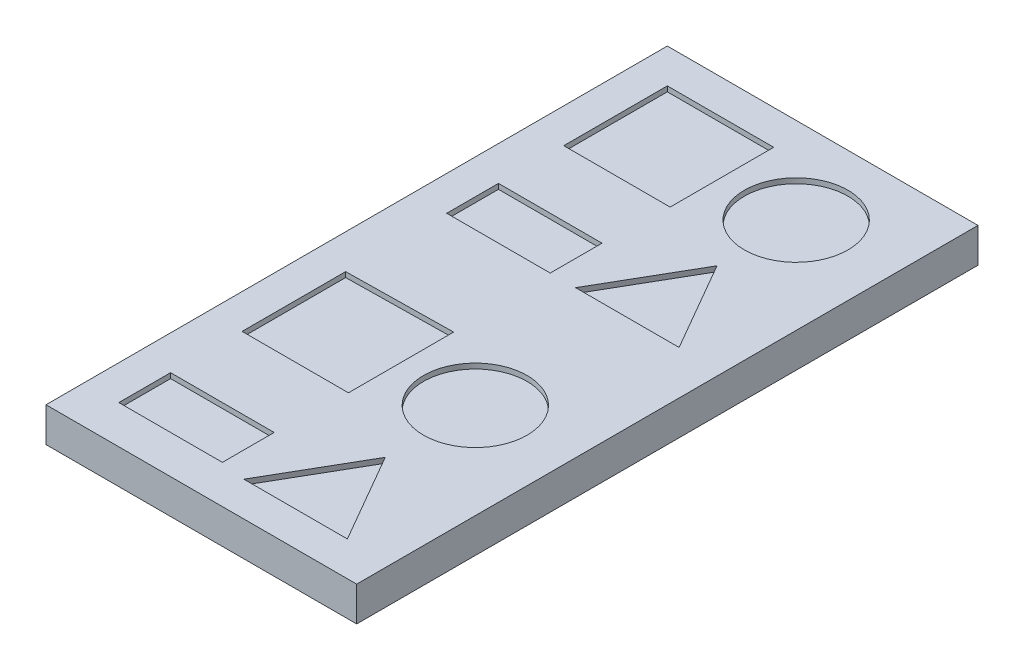
from build123d import *

# Parameters (mm, degrees)
SKETCH1_W           = 180
SKETCH1_H           = 360
BOSS_EXTRUDE1_DEPTH = 20
SKETCH2_R           = 30
SKETCH2_W           = 60
SKETCH2_H           = 30
SKETCH2_W_2         = 61.624654561
SKETCH2_H_2         = 60
CUT_EXTRUDE1_DEPTH  = 3


with BuildPart() as part:
    # Sketch1 → Boss-Extrude1 (new body)
    with BuildSketch(Plane(origin=(0, 0, 0), x_dir=(1, 0, 0), z_dir=(0, 1, 0))):
        Rectangle(SKETCH1_W, SKETCH1_H)
    extrude(amount=-BOSS_EXTRUDE1_DEPTH)

    # Sketch2 → Cut-Extrude1 (cut)
    with BuildSketch(Plane(origin=(0, 0, 0), x_dir=(1, 0, 0), z_dir=(0, 1, 0))):
        with Locations((34.656170811, 130)):
            Circle(SKETCH2_R)
        with Locations((34.656170811, -55.914468779)):
            Circle(SKETCH2_R)
        with Locations((-40, 47.162192329)):
            Rectangle(SKETCH2_W, SKETCH2_H)
        with Locations((-39.18767272, 130)):
            Rectangle(SKETCH2_W_2, SKETCH2_H_2)
        Polygon((4.656170811, 32.162192329), (64.656170811, 32.162192329), (34.656170811, 84.123716556), align=None)
        Polygon((4.656170811, -160.040110734), (64.656170811, -160.040110734), (34.656170811, -108.078586507), align=None)
        with Locations((-40, -142.801384824)):
            Rectangle(SKETCH2_W, SKETCH2_H)
        Polygon((-8.375345439, -25.441495932), (-8.375345439, -86.387441626), (-70, -86.387441626), (-70, -26.387441626), align=None)
    extrude(amount=-CUT_EXTRUDE1_DEPTH, mode=Mode.SUBTRACT)


solid = part.part
